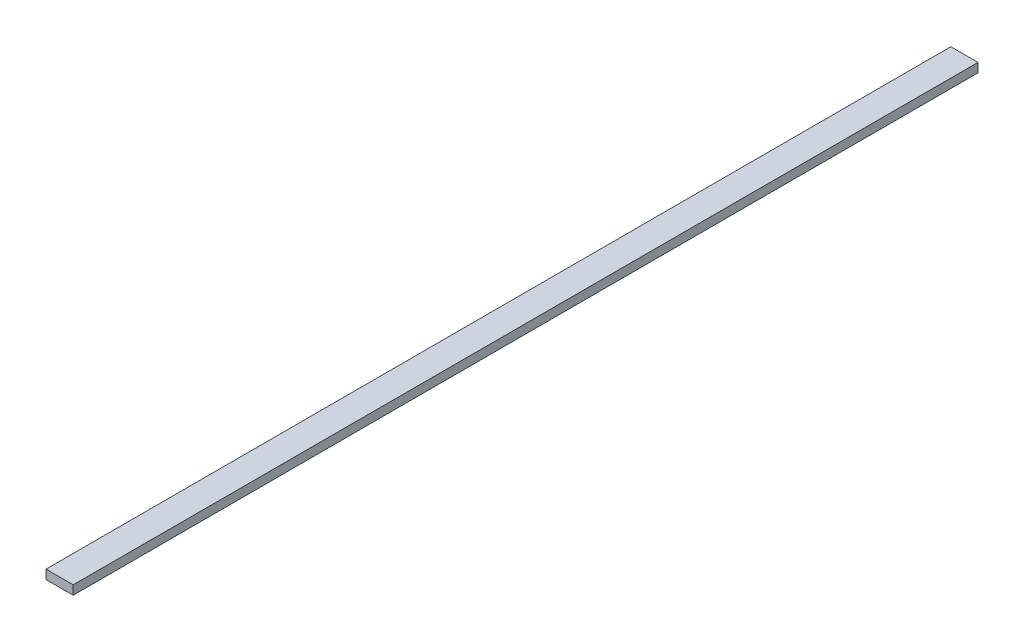
from build123d import *

# Parameters (mm, degrees)
SKETCH1_W           = 300
SKETCH1_H           = 10000
BOSS_EXTRUDE1_DEPTH = 100


with BuildPart() as part:
    # Sketch1 → Boss-Extrude1 (new body)
    with BuildSketch(Plane(origin=(0, 0, 0), x_dir=(1, 0, 0), z_dir=(0, 1, 0))):
        Rectangle(SKETCH1_W, SKETCH1_H)
    extrude(amount=BOSS_EXTRUDE1_DEPTH)


solid = part.part
